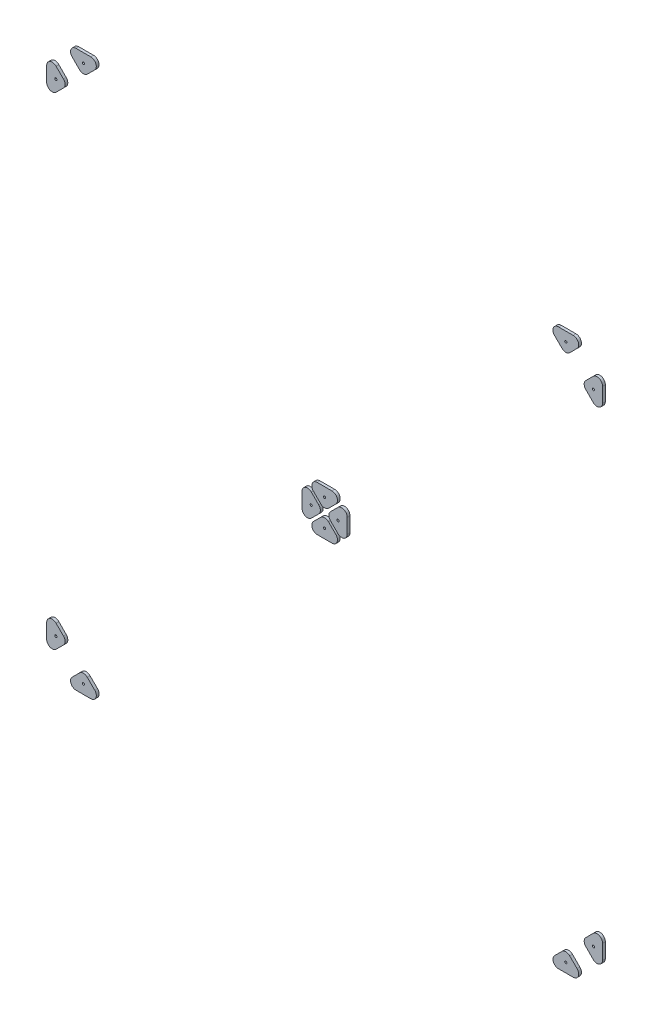
from build123d import *

# Parameters (mm, degrees)
SKETCH1_R              = 2.4
BOSS_EXTRUDE1_DEPTH    = 6
BOSS_EXTRUDE1_2_DEPTH  = 6
BOSS_EXTRUDE1_3_DEPTH  = 6
BOSS_EXTRUDE1_4_DEPTH  = 6
BOSS_EXTRUDE1_5_DEPTH  = 6
BOSS_EXTRUDE1_6_DEPTH  = 6
BOSS_EXTRUDE1_7_DEPTH  = 6
BOSS_EXTRUDE1_8_DEPTH  = 6
BOSS_EXTRUDE1_9_DEPTH  = 6
BOSS_EXTRUDE1_10_DEPTH = 6
BOSS_EXTRUDE1_11_DEPTH = 6
BOSS_EXTRUDE1_12_DEPTH = 6


with BuildPart() as part:
    # Sketch1 → Boss-Extrude1 (new body)
    with BuildSketch(Plane.XY):
        with BuildLine():
            Line((549.514718626, -584.514718626), (533.485281374, -568.485281374))
            ThreePointArc((533.485281374, -568.485281374), (525, -564.970562748), (516.514718626, -568.485281374))
            Line((516.514718626, -568.485281374), (500.485281374, -584.514718626))
            ThreePointArc((500.485281374, -584.514718626), (497.884008358, -597.592201188), (508.970562748, -605))
            Line((508.970562748, -605), (541.029437252, -605))
            ThreePointArc((541.029437252, -605), (552.115991642, -597.592201188), (549.514718626, -584.514718626))
        make_face()
        with Locations((525, -585)):
            Circle(SKETCH1_R, mode=Mode.SUBTRACT)
    extrude(amount=-BOSS_EXTRUDE1_DEPTH)


with BuildPart() as body_2:
    # Sketch1 → Boss-Extrude1 2 (new body)
    with BuildSketch(Plane.XY):
        with BuildLine():
            Line((605, -508.970562748), (605, -541.029437252))
            ThreePointArc((605, -541.029437252), (597.592201188, -552.115991642), (584.514718626, -549.514718626))
            Line((584.514718626, -549.514718626), (568.485281374, -533.485281374))
            ThreePointArc((568.485281374, -533.485281374), (564.970562748, -525), (568.485281374, -516.514718626))
            Line((568.485281374, -516.514718626), (584.514718626, -500.485281374))
            ThreePointArc((584.514718626, -500.485281374), (597.592201188, -497.884008358), (605, -508.970562748))
        make_face()
        with Locations((585, -525)):
            Circle(SKETCH1_R, mode=Mode.SUBTRACT)
    extrude(amount=-BOSS_EXTRUDE1_2_DEPTH)


with BuildPart() as body_3:
    # Sketch1 → Boss-Extrude1 3 (new body)
    with BuildSketch(Plane.XY):
        with BuildLine():
            Line((-584.514718626, -549.514718626), (-568.485281374, -533.485281374))
            ThreePointArc((-568.485281374, -533.485281374), (-564.970562748, -525), (-568.485281374, -516.514718626))
            Line((-568.485281374, -516.514718626), (-584.514718626, -500.485281374))
            ThreePointArc((-584.514718626, -500.485281374), (-597.592201188, -497.884008358), (-605, -508.970562748))
            Line((-605, -508.970562748), (-605, -541.029437252))
            ThreePointArc((-605, -541.029437252), (-597.592201188, -552.115991642), (-584.514718626, -549.514718626))
        make_face()
        with Locations((-585, -525)):
            Circle(SKETCH1_R, mode=Mode.SUBTRACT)
    extrude(amount=-BOSS_EXTRUDE1_3_DEPTH)


with BuildPart() as body_4:
    # Sketch1 → Boss-Extrude1 4 (new body)
    with BuildSketch(Plane.XY):
        with BuildLine():
            Line((-508.970562748, -605), (-541.029437252, -605))
            ThreePointArc((-541.029437252, -605), (-552.115991642, -597.592201188), (-549.514718626, -584.514718626))
            Line((-549.514718626, -584.514718626), (-533.485281374, -568.485281374))
            ThreePointArc((-533.485281374, -568.485281374), (-525, -564.970562748), (-516.514718626, -568.485281374))
            Line((-516.514718626, -568.485281374), (-500.485281374, -584.514718626))
            ThreePointArc((-500.485281374, -584.514718626), (-497.884008358, -597.592201188), (-508.970562748, -605))
        make_face()
        with Locations((-525, -585)):
            Circle(SKETCH1_R, mode=Mode.SUBTRACT)
    extrude(amount=-BOSS_EXTRUDE1_4_DEPTH)


with BuildPart() as body_5:
    # Sketch1 → Boss-Extrude1 5 (new body)
    with BuildSketch(Plane.XY):
        with BuildLine():
            Line((-549.514718626, 584.514718626), (-533.485281374, 568.485281374))
            ThreePointArc((-533.485281374, 568.485281374), (-525, 564.970562748), (-516.514718626, 568.485281374))
            Line((-516.514718626, 568.485281374), (-500.485281374, 584.514718626))
            ThreePointArc((-500.485281374, 584.514718626), (-497.884008358, 597.592201188), (-508.970562748, 605))
            Line((-508.970562748, 605), (-541.029437252, 605))
            ThreePointArc((-541.029437252, 605), (-552.115991642, 597.592201188), (-549.514718626, 584.514718626))
        make_face()
        with Locations((-525, 585)):
            Circle(SKETCH1_R, mode=Mode.SUBTRACT)
    extrude(amount=-BOSS_EXTRUDE1_5_DEPTH)


with BuildPart() as body_6:
    # Sketch1 → Boss-Extrude1 6 (new body)
    with BuildSketch(Plane.XY):
        with BuildLine():
            Line((-605, 508.970562748), (-605, 541.029437252))
            ThreePointArc((-605, 541.029437252), (-597.592201188, 552.115991642), (-584.514718626, 549.514718626))
            Line((-584.514718626, 549.514718626), (-568.485281374, 533.485281374))
            ThreePointArc((-568.485281374, 533.485281374), (-564.970562748, 525), (-568.485281374, 516.514718626))
            Line((-568.485281374, 516.514718626), (-584.514718626, 500.485281374))
            ThreePointArc((-584.514718626, 500.485281374), (-597.592201188, 497.884008358), (-605, 508.970562748))
        make_face()
        with Locations((-585, 525)):
            Circle(SKETCH1_R, mode=Mode.SUBTRACT)
    extrude(amount=-BOSS_EXTRUDE1_6_DEPTH)


with BuildPart() as body_7:
    # Sketch1 → Boss-Extrude1 7 (new body)
    with BuildSketch(Plane.XY):
        with BuildLine():
            Line((584.514718626, 549.514718626), (568.485281374, 533.485281374))
            ThreePointArc((568.485281374, 533.485281374), (564.970562748, 525), (568.485281374, 516.514718626))
            Line((568.485281374, 516.514718626), (584.514718626, 500.485281374))
            ThreePointArc((584.514718626, 500.485281374), (597.592201188, 497.884008358), (605, 508.970562748))
            Line((605, 508.970562748), (605, 541.029437252))
            ThreePointArc((605, 541.029437252), (597.592201188, 552.115991642), (584.514718626, 549.514718626))
        make_face()
        with Locations((585, 525)):
            Circle(SKETCH1_R, mode=Mode.SUBTRACT)
    extrude(amount=-BOSS_EXTRUDE1_7_DEPTH)


with BuildPart() as body_8:
    # Sketch1 → Boss-Extrude1 8 (new body)
    with BuildSketch(Plane.XY):
        with BuildLine():
            Line((508.970562748, 605), (541.029437252, 605))
            ThreePointArc((541.029437252, 605), (552.115991642, 597.592201188), (549.514718626, 584.514718626))
            Line((549.514718626, 584.514718626), (533.485281374, 568.485281374))
            ThreePointArc((533.485281374, 568.485281374), (525, 564.970562748), (516.514718626, 568.485281374))
            Line((516.514718626, 568.485281374), (500.485281374, 584.514718626))
            ThreePointArc((500.485281374, 584.514718626), (497.884008358, 597.592201188), (508.970562748, 605))
        make_face()
        with Locations((525, 585)):
            Circle(SKETCH1_R, mode=Mode.SUBTRACT)
    extrude(amount=-BOSS_EXTRUDE1_8_DEPTH)


with BuildPart() as body_9:
    # Sketch1 → Boss-Extrude1 9 (new body)
    with BuildSketch(Plane.XY):
        with BuildLine():
            Line((16.029437252, -49.242640687), (-16.029437252, -49.242640687))
            ThreePointArc((-16.029437252, -49.242640687), (-27.115991642, -41.834841876), (-24.514718626, -28.757359313))
            Line((-24.514718626, -28.757359313), (-8.485281374, -12.727922061))
            ThreePointArc((-8.485281374, -12.727922061), (0, -9.213203436), (8.485281374, -12.727922061))
            Line((8.485281374, -12.727922061), (24.514718626, -28.757359313))
            ThreePointArc((24.514718626, -28.757359313), (27.115991642, -41.834841876), (16.029437252, -49.242640687))
        make_face()
        with Locations((0, -29.242640687)):
            Circle(SKETCH1_R, mode=Mode.SUBTRACT)
    extrude(amount=-BOSS_EXTRUDE1_9_DEPTH)


with BuildPart() as body_10:
    # Sketch1 → Boss-Extrude1 10 (new body)
    with BuildSketch(Plane.XY):
        with BuildLine():
            Line((12.727922061, -8.485281374), (28.757359313, -24.514718626))
            ThreePointArc((28.757359313, -24.514718626), (41.834841876, -27.115991642), (49.242640687, -16.029437252))
            Line((49.242640687, -16.029437252), (49.242640687, 16.029437252))
            ThreePointArc((49.242640687, 16.029437252), (41.834841876, 27.115991642), (28.757359313, 24.514718626))
            Line((28.757359313, 24.514718626), (12.727922061, 8.485281374))
            ThreePointArc((12.727922061, 8.485281374), (9.213203436, 0), (12.727922061, -8.485281374))
        make_face()
        with Locations((29.242640687, 0)):
            Circle(SKETCH1_R, mode=Mode.SUBTRACT)
    extrude(amount=-BOSS_EXTRUDE1_10_DEPTH)


with BuildPart() as body_11:
    # Sketch1 → Boss-Extrude1 11 (new body)
    with BuildSketch(Plane.XY):
        with BuildLine():
            Line((-16.029437252, 49.242640687), (16.029437252, 49.242640687))
            ThreePointArc((16.029437252, 49.242640687), (27.115991642, 41.834841876), (24.514718626, 28.757359313))
            Line((24.514718626, 28.757359313), (8.485281374, 12.727922061))
            ThreePointArc((8.485281374, 12.727922061), (0, 9.213203436), (-8.485281374, 12.727922061))
            Line((-8.485281374, 12.727922061), (-24.514718626, 28.757359313))
            ThreePointArc((-24.514718626, 28.757359313), (-27.115991642, 41.834841876), (-16.029437252, 49.242640687))
        make_face()
        with Locations((0, 29.242640687)):
            Circle(SKETCH1_R, mode=Mode.SUBTRACT)
    extrude(amount=-BOSS_EXTRUDE1_11_DEPTH)


with BuildPart() as body_12:
    # Sketch1 → Boss-Extrude1 12 (new body)
    with BuildSketch(Plane.XY):
        with BuildLine():
            Line((-12.727922061, 8.485281374), (-28.757359313, 24.514718626))
            ThreePointArc((-28.757359313, 24.514718626), (-41.834841876, 27.115991642), (-49.242640687, 16.029437252))
            Line((-49.242640687, 16.029437252), (-49.242640687, -16.029437252))
            ThreePointArc((-49.242640687, -16.029437252), (-41.834841876, -27.115991642), (-28.757359313, -24.514718626))
            Line((-28.757359313, -24.514718626), (-12.727922061, -8.485281374))
            ThreePointArc((-12.727922061, -8.485281374), (-9.213203436, 0), (-12.727922061, 8.485281374))
        make_face()
        with Locations((-29.242640687, 0)):
            Circle(SKETCH1_R, mode=Mode.SUBTRACT)
    extrude(amount=-BOSS_EXTRUDE1_12_DEPTH)


solid = Compound([part.part, body_2.part, body_3.part, body_4.part, body_5.part, body_6.part, body_7.part, body_8.part, body_9.part, body_10.part, body_11.part, body_12.part])
